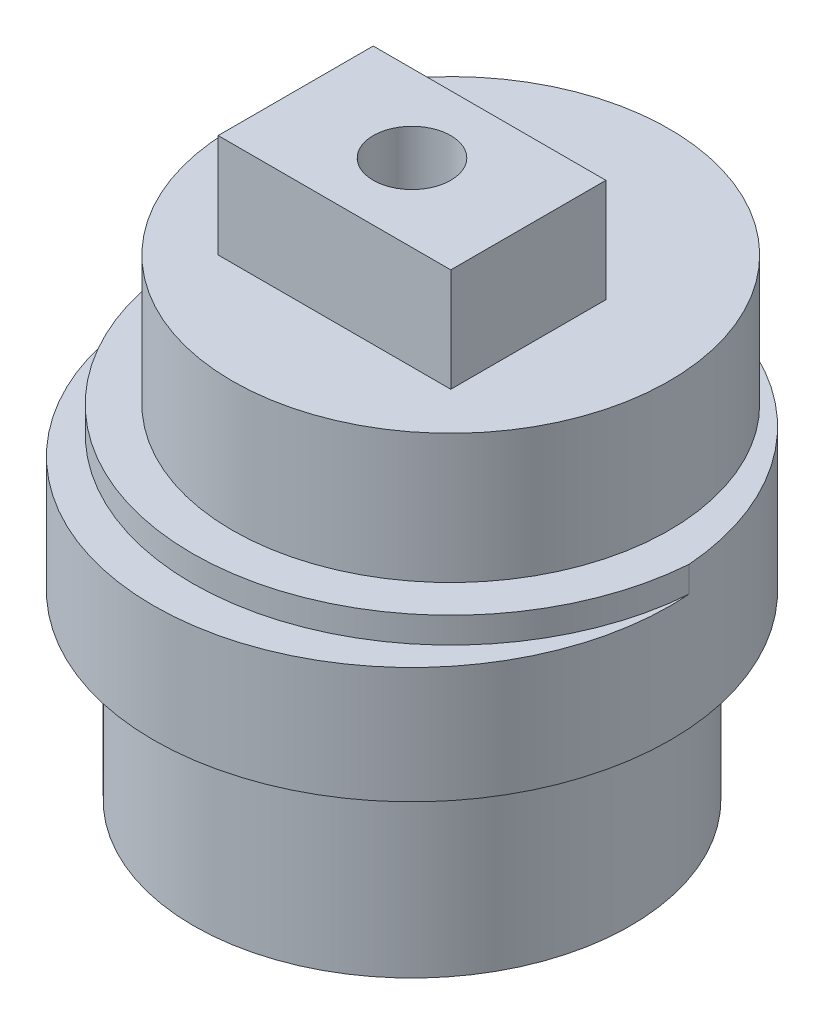
from build123d import *

# Parameters (mm, degrees)
SKETCH1_R           = 8.45
BOSS_EXTRUDE1_DEPTH = 7
SKETCH2_R           = 10
BOSS_EXTRUDE2_DEPTH = 4.5
SKETCH3_R           = 8.45
BOSS_EXTRUDE3_DEPTH = 6
SKETCH4_R           = 8.45
BOSS_EXTRUDE4_DEPTH = 1
SKETCH5_W           = 9
SKETCH5_H           = 6
BOSS_EXTRUDE5_DEPTH = 4
SKETCH6_R           = 1.5
CUT_EXTRUDE1_DEPTH  = 8
CUT_EXTRUDE3_DEPTH  = 16


with BuildPart() as part:
    # Sketch1 → Boss-Extrude1 (new body)
    with BuildSketch(Plane(origin=(0, 0, 0), x_dir=(1, 0, 0), z_dir=(0, 1, 0))):
        Circle(SKETCH1_R)
    extrude(amount=BOSS_EXTRUDE1_DEPTH)

    # Sketch2 → Boss-Extrude2 (add)
    with BuildSketch(Plane(origin=(0, 7, 0), x_dir=(1, 0, 0), z_dir=(0, 1, 0))):
        Circle(SKETCH2_R)
    extrude(amount=BOSS_EXTRUDE2_DEPTH)

    # Sketch3 → Boss-Extrude3 (add)
    with BuildSketch(Plane(origin=(0, 11.5, 0), x_dir=(1, 0, 0), z_dir=(0, 1, 0))):
        with Locations((0, 1.5)):
            Circle(SKETCH3_R)
    extrude(amount=BOSS_EXTRUDE3_DEPTH)

    # Sketch4 → Boss-Extrude4 (add)
    with BuildSketch(Plane(origin=(0, 11.5, 0), x_dir=(1, 0, 0), z_dir=(0, 1, 0))):
        with BuildLine():
            ThreePointArc((9.971835338, 0.75), (0, 10), (-9.971835338, 0.75))
            ThreePointArc((-9.971835338, 0.75), (0, -8.5), (9.971835338, 0.75))
        make_face()
        with Locations((0, 1.5)):
            Circle(SKETCH4_R, mode=Mode.SUBTRACT)
    extrude(amount=BOSS_EXTRUDE4_DEPTH)

    # Sketch5 → Boss-Extrude5 (add)
    with BuildSketch(Plane(origin=(0, 17.5, 0), x_dir=(1, 0, 0), z_dir=(0, 1, 0))):
        Rectangle(SKETCH5_W, SKETCH5_H)
    extrude(amount=BOSS_EXTRUDE5_DEPTH)

    # Sketch6 → Cut-Extrude1 (cut)
    with BuildSketch(Plane(origin=(0, 21.5, 0), x_dir=(1, 0, 0), z_dir=(0, 1, 0))):
        Circle(SKETCH6_R)
    extrude(amount=-CUT_EXTRUDE1_DEPTH, mode=Mode.SUBTRACT)

    # Sketch8 → Cut-Extrude3 (cut)
    with BuildSketch(Plane.XZ):
        with BuildLine():
            ThreePointArc((1.943316155, 2.925914586), (1.699048653, 3.074197053), (1.443536153, 3.202133229))
            add(Edge.make_bspline(
                [(1.443536153, 3.202133229), (1.444031707, 3.223830116), (1.44398849, 3.268683064), (1.440824568, 3.338668541), (1.434115766, 3.41398948), (1.423301357, 3.49507766), (1.407896176, 3.581722393), (1.387267561, 3.673599968), (1.361458781, 3.770678005), (1.325563984, 3.878324655), (1.299816317, 3.963754312), (1.269287176, 4.016921178), (1.254329579, 4.036617994), (1.237294912, 4.054558617), (1.218164406, 4.070191292), (1.19356956, 4.087238463), (1.163917734, 4.095781007), (1.134023041, 4.094432002), (1.109507694, 4.09137348), (1.085539043, 4.08524571), (1.062394745, 4.076525861), (1.008258504, 4.04775067), (0.941006014, 3.989113898), (0.85334155, 3.917064057), (0.779840002, 3.848596833), (0.713491437, 3.781776952), (0.65434972, 3.71660881), (0.602051386, 3.653703098), (0.556297725, 3.593496334), (0.516384238, 3.535921245), (0.492484438, 3.497966161), (0.481360595, 3.479331232)],
                knots=[0.027203348, 0.027203348, 0.027203348, 0.027203348, 0.05931822, 0.093555562, 0.130845058, 0.171186709, 0.214580515, 0.261026475, 0.31052459, 0.363074859, 0.429245309, 0.441417135, 0.453588962, 0.465760788, 0.477932615, 0.490104441, 0.509895559, 0.522067385, 0.534239212, 0.546411038, 0.558582865, 0.570754691, 0.636925141, 0.68947541, 0.738973525, 0.785419485, 0.828813291, 0.869154942, 0.906444438, 0.94068178, 0.972796652, 0.972796652, 0.972796652, 0.972796652], degree=3, weights=[1, 1, 1, 1, 1, 1, 1, 1, 1, 1, 1, 1, 1, 1, 1, 1, 1, 1, 1, 1, 1, 1, 1, 1, 1, 1, 1, 1, 1, 1, 1, 1]))
            ThreePointArc((0.481360595, 3.479331232), (0.196945829, 3.506945421), (-0.088772405, 3.511349214))
            add(Edge.make_bspline(
                [(-0.088772405, 3.511349214), (-0.097739853, 3.531112446), (-0.117239755, 3.571504805), (-0.15045591, 3.633186767), (-0.189180863, 3.698137748), (-0.234107151, 3.766503478), (-0.28558048, 3.837883627), (-0.344030407, 3.911712041), (-0.409403895, 3.98797832), (-0.48845012, 4.069390432), (-0.548714506, 4.135188398), (-0.59928855, 4.169843992), (-0.621311008, 4.181100352), (-0.644442858, 4.18987323), (-0.668461611, 4.195657368), (-0.698017292, 4.200345035), (-0.728439135, 4.195176156), (-0.754788011, 4.180989923), (-0.775548532, 4.16759748), (-0.794484801, 4.151676941), (-0.811553693, 4.133778694), (-0.847843672, 4.084364309), (-0.882994531, 4.00235464), (-0.930716229, 3.899403792), (-0.96723202, 3.805825828), (-0.998017952, 3.716835632), (-1.023027401, 3.632460536), (-1.042852806, 3.55309305), (-1.057952694, 3.478996861), (-1.068932609, 3.409805685), (-1.073997491, 3.365239602), (-1.075934334, 3.343623656)],
                knots=[0.027203348, 0.027203348, 0.027203348, 0.027203348, 0.05931822, 0.093555562, 0.130845058, 0.171186709, 0.214580515, 0.261026475, 0.31052459, 0.363074859, 0.429245309, 0.441417135, 0.453588962, 0.465760788, 0.477932615, 0.490104441, 0.509895559, 0.522067385, 0.534239212, 0.546411038, 0.558582865, 0.570754691, 0.636925141, 0.68947541, 0.738973525, 0.785419485, 0.828813291, 0.869154942, 0.906444438, 0.94068178, 0.972796652, 0.972796652, 0.972796652, 0.972796652], degree=3, weights=[1, 1, 1, 1, 1, 1, 1, 1, 1, 1, 1, 1, 1, 1, 1, 1, 1, 1, 1, 1, 1, 1, 1, 1, 1, 1, 1, 1, 1, 1, 1, 1]))
            ThreePointArc((-1.075934334, 3.343623656), (-1.344164531, 3.245100238), (-1.603498499, 3.125099423))
            add(Edge.make_bspline(
                [(-1.603498499, 3.125099423), (-1.620152836, 3.13901465), (-1.655247228, 3.166946218), (-1.71193675, 3.208107795), (-1.775007901, 3.24982448), (-1.845147867, 3.291927088), (-1.922494421, 3.33390494), (-2.007188933, 3.37506157), (-2.099179109, 3.415410619), (-2.205720688, 3.454463526), (-2.288565692, 3.487597708), (-2.349167829, 3.496878064), (-2.37389333, 3.497464507), (-2.398540815, 3.495332064), (-2.422690608, 3.490122045), (-2.451353259, 3.481521758), (-2.476519699, 3.463665216), (-2.49410404, 3.439451513), (-2.506997861, 3.418377686), (-2.517151187, 3.395817637), (-2.524763968, 3.372285959), (-2.536020012, 3.312019505), (-2.532107179, 3.22287996), (-2.530434245, 3.109418782), (-2.522731879, 3.009264342), (-2.511857646, 2.915729431), (-2.497781398, 2.828858903), (-2.48120721, 2.748749348), (-2.462662608, 2.675439393), (-2.442534243, 2.608336291), (-2.427761045, 2.565986067), (-2.420127273, 2.545670408)],
                knots=[0.027203348, 0.027203348, 0.027203348, 0.027203348, 0.05931822, 0.093555562, 0.130845058, 0.171186709, 0.214580515, 0.261026475, 0.31052459, 0.363074859, 0.429245309, 0.441417135, 0.453588962, 0.465760788, 0.477932615, 0.490104441, 0.509895559, 0.522067385, 0.534239212, 0.546411038, 0.558582865, 0.570754691, 0.636925141, 0.68947541, 0.738973525, 0.785419485, 0.828813291, 0.869154942, 0.906444438, 0.94068178, 0.972796652, 0.972796652, 0.972796652, 0.972796652], degree=3, weights=[1, 1, 1, 1, 1, 1, 1, 1, 1, 1, 1, 1, 1, 1, 1, 1, 1, 1, 1, 1, 1, 1, 1, 1, 1, 1, 1, 1, 1, 1, 1, 1]))
            ThreePointArc((-2.420127273, 2.545670408), (-2.619046621, 2.340523155), (-2.800632051, 2.119885365))
            add(Edge.make_bspline(
                [(-2.800632051, 2.119885365), (-2.82167468, 2.125196505), (-2.865412688, 2.135135092), (-2.934347522, 2.14762373), (-3.009272856, 2.157843617), (-3.090734419, 2.165344166), (-3.178634763, 2.169605492), (-3.272799074, 2.169938763), (-3.373186155, 2.166378958), (-3.486121223, 2.155337752), (-3.575138375, 2.149245519), (-3.63376561, 2.131312549), (-3.656296964, 2.121112923), (-3.677578348, 2.108497515), (-3.697076017, 2.093325248), (-3.719168648, 2.073140399), (-3.734095165, 2.046132902), (-3.739432177, 2.016687549), (-3.741905517, 1.992106268), (-3.741264909, 1.967375003), (-3.737913776, 1.942870632), (-3.721906486, 1.883688618), (-3.679704947, 1.805074378), (-3.628968725, 1.703575248), (-3.57857375, 1.616681147), (-3.528193127, 1.537127257), (-3.477819157, 1.46496707), (-3.428128096, 1.399982127), (-3.379611989, 1.341978341), (-3.332362014, 1.290253905), (-3.300676749, 1.258507522), (-3.284984324, 1.243515915)],
                knots=[0.027203348, 0.027203348, 0.027203348, 0.027203348, 0.05931822, 0.093555562, 0.130845058, 0.171186709, 0.214580515, 0.261026475, 0.31052459, 0.363074859, 0.429245309, 0.441417135, 0.453588962, 0.465760788, 0.477932615, 0.490104441, 0.509895559, 0.522067385, 0.534239212, 0.546411038, 0.558582865, 0.570754691, 0.636925141, 0.68947541, 0.738973525, 0.785419485, 0.828813291, 0.869154942, 0.906444438, 0.94068178, 0.972796652, 0.972796652, 0.972796652, 0.972796652], degree=3, weights=[1, 1, 1, 1, 1, 1, 1, 1, 1, 1, 1, 1, 1, 1, 1, 1, 1, 1, 1, 1, 1, 1, 1, 1, 1, 1, 1, 1, 1, 1, 1, 1]))
            ThreePointArc((-3.284984324, 1.243515915), (-3.375194407, 0.972376756), (-3.443066077, 0.694802011))
            add(Edge.make_bspline(
                [(-3.443066077, 0.694802011), (-3.464329248, 0.690457129), (-3.508048023, 0.680434275), (-3.575574779, 0.661776446), (-3.647514416, 0.638475362), (-3.724163113, 0.609888276), (-3.805207507, 0.575589068), (-3.890191221, 0.535032971), (-3.979092314, 0.488269375), (-4.076052694, 0.429320903), (-4.153611056, 0.385208897), (-4.198651546, 0.343614445), (-4.214526143, 0.324648911), (-4.228226387, 0.304049175), (-4.23921018, 0.281919713), (-4.250357075, 0.254148159), (-4.252087287, 0.223338872), (-4.244119909, 0.194493883), (-4.235682894, 0.171273772), (-4.224375232, 0.149269622), (-4.210723917, 0.128645949), (-4.170623734, 0.082270099), (-4.098492021, 0.029751678), (-4.008741442, -0.039682257), (-3.925635201, -0.096105576), (-3.845726689, -0.145921822), (-3.769032179, -0.189079457), (-3.69606617, -0.226068725), (-3.627187768, -0.25727798), (-3.56217462, -0.283379091), (-3.519852944, -0.298233872), (-3.499209943, -0.304932155)],
                knots=[0.027203348, 0.027203348, 0.027203348, 0.027203348, 0.05931822, 0.093555562, 0.130845058, 0.171186709, 0.214580515, 0.261026475, 0.31052459, 0.363074859, 0.429245309, 0.441417135, 0.453588962, 0.465760788, 0.477932615, 0.490104441, 0.509895559, 0.522067385, 0.534239212, 0.546411038, 0.558582865, 0.570754691, 0.636925141, 0.68947541, 0.738973525, 0.785419485, 0.828813291, 0.869154942, 0.906444438, 0.94068178, 0.972796652, 0.972796652, 0.972796652, 0.972796652], degree=3, weights=[1, 1, 1, 1, 1, 1, 1, 1, 1, 1, 1, 1, 1, 1, 1, 1, 1, 1, 1, 1, 1, 1, 1, 1, 1, 1, 1, 1, 1, 1, 1, 1]))
            ThreePointArc((-3.499209943, -0.304932155), (-3.462843547, -0.588360784), (-3.40355864, -0.867895402))
            add(Edge.make_bspline(
                [(-3.40355864, -0.867895402), (-3.420830922, -0.88103575), (-3.455871423, -0.909034894), (-3.5086156, -0.955143779), (-3.563321011, -1.007350769), (-3.61997563, -1.066363467), (-3.678112237, -1.132429831), (-3.737083286, -1.205842663), (-3.79689044, -1.286547945), (-3.858671941, -1.381728216), (-3.909410127, -1.455123072), (-3.93194305, -1.512140715), (-3.938016731, -1.5361158), (-3.941422334, -1.560619834), (-3.941716776, -1.585323479), (-3.939710156, -1.615181241), (-3.927901374, -1.643690161), (-3.908207643, -1.666221682), (-3.890531326, -1.683481595), (-3.870796232, -1.698400439), (-3.849548546, -1.711058643), (-3.793297802, -1.735443022), (-3.705522485, -1.751463707), (-3.594533753, -1.775080204), (-3.495176456, -1.789857412), (-3.401566916, -1.800069294), (-3.313742153, -1.805676479), (-3.231953009, -1.807343893), (-3.156354525, -1.805577242), (-3.086454855, -1.800885382), (-3.041879094, -1.795906391), (-3.020374117, -1.792984673)],
                knots=[0.027203348, 0.027203348, 0.027203348, 0.027203348, 0.05931822, 0.093555562, 0.130845058, 0.171186709, 0.214580515, 0.261026475, 0.31052459, 0.363074859, 0.429245309, 0.441417135, 0.453588962, 0.465760788, 0.477932615, 0.490104441, 0.509895559, 0.522067385, 0.534239212, 0.546411038, 0.558582865, 0.570754691, 0.636925141, 0.68947541, 0.738973525, 0.785419485, 0.828813291, 0.869154942, 0.906444438, 0.94068178, 0.972796652, 0.972796652, 0.972796652, 0.972796652], degree=3, weights=[1, 1, 1, 1, 1, 1, 1, 1, 1, 1, 1, 1, 1, 1, 1, 1, 1, 1, 1, 1, 1, 1, 1, 1, 1, 1, 1, 1, 1, 1, 1, 1]))
            ThreePointArc((-3.020374117, -1.792984673), (-2.864634053, -2.032566256), (-2.689934673, -2.258695486))
            add(Edge.make_bspline(
                [(-2.689934673, -2.258695486), (-2.699795077, -2.278028694), (-2.719217105, -2.318458555), (-2.746732071, -2.382886065), (-2.773368179, -2.453658726), (-2.798807576, -2.531408848), (-2.822521729, -2.616157113), (-2.843800174, -2.707886368), (-2.862667848, -2.806548667), (-2.877033885, -2.919109116), (-2.890902577, -3.007250071), (-2.886465011, -3.06839786), (-2.881534809, -3.092633937), (-2.873971249, -3.116188945), (-2.863518022, -3.138573914), (-2.848755322, -3.164604188), (-2.825746421, -3.185166199), (-2.798226922, -3.196921608), (-2.774812315, -3.204802786), (-2.750558566, -3.209681463), (-2.725922874, -3.211867086), (-2.664662719, -3.209430369), (-2.578628776, -3.185780225), (-2.46838457, -3.158901747), (-2.372455148, -3.129106036), (-2.283685097, -3.097690966), (-2.202124854, -3.064637129), (-2.127711918, -3.030652437), (-2.060366558, -2.996259787), (-1.999424853, -2.961704237), (-1.961423784, -2.937877623), (-1.943316155, -2.925914586)],
                knots=[0.027203348, 0.027203348, 0.027203348, 0.027203348, 0.05931822, 0.093555562, 0.130845058, 0.171186709, 0.214580515, 0.261026475, 0.31052459, 0.363074859, 0.429245309, 0.441417135, 0.453588962, 0.465760788, 0.477932615, 0.490104441, 0.509895559, 0.522067385, 0.534239212, 0.546411038, 0.558582865, 0.570754691, 0.636925141, 0.68947541, 0.738973525, 0.785419485, 0.828813291, 0.869154942, 0.906444438, 0.94068178, 0.972796652, 0.972796652, 0.972796652, 0.972796652], degree=3, weights=[1, 1, 1, 1, 1, 1, 1, 1, 1, 1, 1, 1, 1, 1, 1, 1, 1, 1, 1, 1, 1, 1, 1, 1, 1, 1, 1, 1, 1, 1, 1, 1]))
            ThreePointArc((-1.943316155, -2.925914586), (-1.699048653, -3.074197053), (-1.443536153, -3.202133229))
            add(Edge.make_bspline(
                [(-1.443536153, -3.202133229), (-1.444031707, -3.223830116), (-1.44398849, -3.268683064), (-1.440824568, -3.338668541), (-1.434115766, -3.41398948), (-1.423301357, -3.49507766), (-1.407896176, -3.581722393), (-1.387267561, -3.673599968), (-1.361458781, -3.770678005), (-1.325563984, -3.878324655), (-1.299816317, -3.963754312), (-1.269287176, -4.016921178), (-1.254329579, -4.036617994), (-1.237294912, -4.054558617), (-1.218164406, -4.070191292), (-1.19356956, -4.087238463), (-1.163917734, -4.095781007), (-1.134023041, -4.094432002), (-1.109507694, -4.09137348), (-1.085539043, -4.08524571), (-1.062394745, -4.076525861), (-1.008258504, -4.04775067), (-0.941006014, -3.989113898), (-0.85334155, -3.917064057), (-0.779840002, -3.848596833), (-0.713491437, -3.781776952), (-0.65434972, -3.71660881), (-0.602051386, -3.653703098), (-0.556297725, -3.593496334), (-0.516384238, -3.535921245), (-0.492484438, -3.497966161), (-0.481360595, -3.479331232)],
                knots=[0.027203348, 0.027203348, 0.027203348, 0.027203348, 0.05931822, 0.093555562, 0.130845058, 0.171186709, 0.214580515, 0.261026475, 0.31052459, 0.363074859, 0.429245309, 0.441417135, 0.453588962, 0.465760788, 0.477932615, 0.490104441, 0.509895559, 0.522067385, 0.534239212, 0.546411038, 0.558582865, 0.570754691, 0.636925141, 0.68947541, 0.738973525, 0.785419485, 0.828813291, 0.869154942, 0.906444438, 0.94068178, 0.972796652, 0.972796652, 0.972796652, 0.972796652], degree=3, weights=[1, 1, 1, 1, 1, 1, 1, 1, 1, 1, 1, 1, 1, 1, 1, 1, 1, 1, 1, 1, 1, 1, 1, 1, 1, 1, 1, 1, 1, 1, 1, 1]))
            ThreePointArc((-0.481360595, -3.479331232), (-0.196945829, -3.506945421), (0.088772405, -3.511349214))
            add(Edge.make_bspline(
                [(0.088772405, -3.511349214), (0.097739853, -3.531112446), (0.117239755, -3.571504805), (0.15045591, -3.633186767), (0.189180863, -3.698137748), (0.234107151, -3.766503478), (0.28558048, -3.837883627), (0.344030407, -3.911712041), (0.409403895, -3.98797832), (0.48845012, -4.069390432), (0.548714506, -4.135188398), (0.59928855, -4.169843992), (0.621311008, -4.181100352), (0.644442858, -4.18987323), (0.668461611, -4.195657368), (0.698017292, -4.200345035), (0.728439135, -4.195176156), (0.754788011, -4.180989923), (0.775548532, -4.16759748), (0.794484801, -4.151676941), (0.811553693, -4.133778694), (0.847843672, -4.084364309), (0.882994531, -4.00235464), (0.930716229, -3.899403792), (0.96723202, -3.805825828), (0.998017952, -3.716835632), (1.023027401, -3.632460536), (1.042852806, -3.55309305), (1.057952694, -3.478996861), (1.068932609, -3.409805685), (1.073997491, -3.365239602), (1.075934334, -3.343623656)],
                knots=[0.027203348, 0.027203348, 0.027203348, 0.027203348, 0.05931822, 0.093555562, 0.130845058, 0.171186709, 0.214580515, 0.261026475, 0.31052459, 0.363074859, 0.429245309, 0.441417135, 0.453588962, 0.465760788, 0.477932615, 0.490104441, 0.509895559, 0.522067385, 0.534239212, 0.546411038, 0.558582865, 0.570754691, 0.636925141, 0.68947541, 0.738973525, 0.785419485, 0.828813291, 0.869154942, 0.906444438, 0.94068178, 0.972796652, 0.972796652, 0.972796652, 0.972796652], degree=3, weights=[1, 1, 1, 1, 1, 1, 1, 1, 1, 1, 1, 1, 1, 1, 1, 1, 1, 1, 1, 1, 1, 1, 1, 1, 1, 1, 1, 1, 1, 1, 1, 1]))
            ThreePointArc((1.075934334, -3.343623656), (1.344164531, -3.245100238), (1.603498499, -3.125099423))
            add(Edge.make_bspline(
                [(1.603498499, -3.125099423), (1.620152836, -3.13901465), (1.655247228, -3.166946218), (1.71193675, -3.208107795), (1.775007901, -3.24982448), (1.845147867, -3.291927088), (1.922494421, -3.33390494), (2.007188933, -3.37506157), (2.099179109, -3.415410619), (2.205720688, -3.454463526), (2.288565692, -3.487597708), (2.349167829, -3.496878064), (2.37389333, -3.497464507), (2.398540815, -3.495332064), (2.422690608, -3.490122045), (2.451353259, -3.481521758), (2.476519699, -3.463665216), (2.49410404, -3.439451513), (2.506997861, -3.418377686), (2.517151187, -3.395817637), (2.524763968, -3.372285959), (2.536020012, -3.312019505), (2.532107179, -3.22287996), (2.530434245, -3.109418782), (2.522731879, -3.009264342), (2.511857646, -2.915729431), (2.497781398, -2.828858903), (2.48120721, -2.748749348), (2.462662608, -2.675439393), (2.442534243, -2.608336291), (2.427761045, -2.565986067), (2.420127273, -2.545670408)],
                knots=[0.027203348, 0.027203348, 0.027203348, 0.027203348, 0.05931822, 0.093555562, 0.130845058, 0.171186709, 0.214580515, 0.261026475, 0.31052459, 0.363074859, 0.429245309, 0.441417135, 0.453588962, 0.465760788, 0.477932615, 0.490104441, 0.509895559, 0.522067385, 0.534239212, 0.546411038, 0.558582865, 0.570754691, 0.636925141, 0.68947541, 0.738973525, 0.785419485, 0.828813291, 0.869154942, 0.906444438, 0.94068178, 0.972796652, 0.972796652, 0.972796652, 0.972796652], degree=3, weights=[1, 1, 1, 1, 1, 1, 1, 1, 1, 1, 1, 1, 1, 1, 1, 1, 1, 1, 1, 1, 1, 1, 1, 1, 1, 1, 1, 1, 1, 1, 1, 1]))
            ThreePointArc((2.420127273, -2.545670408), (2.619046621, -2.340523155), (2.800632051, -2.119885365))
            add(Edge.make_bspline(
                [(2.800632051, -2.119885365), (2.82167468, -2.125196505), (2.865412688, -2.135135092), (2.934347522, -2.14762373), (3.009272856, -2.157843617), (3.090734419, -2.165344166), (3.178634763, -2.169605492), (3.272799074, -2.169938763), (3.373186155, -2.166378958), (3.486121223, -2.155337752), (3.575138375, -2.149245519), (3.63376561, -2.131312549), (3.656296964, -2.121112923), (3.677578348, -2.108497515), (3.697076017, -2.093325248), (3.719168648, -2.073140399), (3.734095165, -2.046132902), (3.739432177, -2.016687549), (3.741905517, -1.992106268), (3.741264909, -1.967375003), (3.737913776, -1.942870632), (3.721906486, -1.883688618), (3.679704947, -1.805074378), (3.628968725, -1.703575248), (3.57857375, -1.616681147), (3.528193127, -1.537127257), (3.477819157, -1.46496707), (3.428128096, -1.399982127), (3.379611989, -1.341978341), (3.332362014, -1.290253905), (3.300676749, -1.258507522), (3.284984324, -1.243515915)],
                knots=[0.027203348, 0.027203348, 0.027203348, 0.027203348, 0.05931822, 0.093555562, 0.130845058, 0.171186709, 0.214580515, 0.261026475, 0.31052459, 0.363074859, 0.429245309, 0.441417135, 0.453588962, 0.465760788, 0.477932615, 0.490104441, 0.509895559, 0.522067385, 0.534239212, 0.546411038, 0.558582865, 0.570754691, 0.636925141, 0.68947541, 0.738973525, 0.785419485, 0.828813291, 0.869154942, 0.906444438, 0.94068178, 0.972796652, 0.972796652, 0.972796652, 0.972796652], degree=3, weights=[1, 1, 1, 1, 1, 1, 1, 1, 1, 1, 1, 1, 1, 1, 1, 1, 1, 1, 1, 1, 1, 1, 1, 1, 1, 1, 1, 1, 1, 1, 1, 1]))
            ThreePointArc((3.284984324, -1.243515915), (3.375194407, -0.972376756), (3.443066077, -0.694802011))
            add(Edge.make_bspline(
                [(3.443066077, -0.694802011), (3.464329248, -0.690457129), (3.508048023, -0.680434275), (3.575574779, -0.661776446), (3.647514416, -0.638475362), (3.724163113, -0.609888276), (3.805207507, -0.575589068), (3.890191221, -0.535032971), (3.979092314, -0.488269375), (4.076052694, -0.429320903), (4.153611056, -0.385208897), (4.198651546, -0.343614445), (4.214526143, -0.324648911), (4.228226387, -0.304049175), (4.23921018, -0.281919713), (4.250357075, -0.254148159), (4.252087287, -0.223338872), (4.244119909, -0.194493883), (4.235682894, -0.171273772), (4.224375232, -0.149269622), (4.210723917, -0.128645949), (4.170623734, -0.082270099), (4.098492021, -0.029751678), (4.008741442, 0.039682257), (3.925635201, 0.096105576), (3.845726689, 0.145921822), (3.769032179, 0.189079457), (3.69606617, 0.226068725), (3.627187768, 0.25727798), (3.56217462, 0.283379091), (3.519852944, 0.298233872), (3.499209943, 0.304932155)],
                knots=[0.027203348, 0.027203348, 0.027203348, 0.027203348, 0.05931822, 0.093555562, 0.130845058, 0.171186709, 0.214580515, 0.261026475, 0.31052459, 0.363074859, 0.429245309, 0.441417135, 0.453588962, 0.465760788, 0.477932615, 0.490104441, 0.509895559, 0.522067385, 0.534239212, 0.546411038, 0.558582865, 0.570754691, 0.636925141, 0.68947541, 0.738973525, 0.785419485, 0.828813291, 0.869154942, 0.906444438, 0.94068178, 0.972796652, 0.972796652, 0.972796652, 0.972796652], degree=3, weights=[1, 1, 1, 1, 1, 1, 1, 1, 1, 1, 1, 1, 1, 1, 1, 1, 1, 1, 1, 1, 1, 1, 1, 1, 1, 1, 1, 1, 1, 1, 1, 1]))
            ThreePointArc((3.499209943, 0.304932155), (3.462843547, 0.588360784), (3.40355864, 0.867895402))
            add(Edge.make_bspline(
                [(3.40355864, 0.867895402), (3.420830922, 0.88103575), (3.455871423, 0.909034894), (3.5086156, 0.955143779), (3.563321011, 1.007350769), (3.61997563, 1.066363467), (3.678112237, 1.132429831), (3.737083286, 1.205842663), (3.79689044, 1.286547945), (3.858671941, 1.381728216), (3.909410127, 1.455123072), (3.93194305, 1.512140715), (3.938016731, 1.5361158), (3.941422334, 1.560619834), (3.941716776, 1.585323479), (3.939710156, 1.615181241), (3.927901374, 1.643690161), (3.908207643, 1.666221682), (3.890531326, 1.683481595), (3.870796232, 1.698400439), (3.849548546, 1.711058643), (3.793297802, 1.735443022), (3.705522485, 1.751463707), (3.594533753, 1.775080204), (3.495176456, 1.789857412), (3.401566916, 1.800069294), (3.313742153, 1.805676479), (3.231953009, 1.807343893), (3.156354525, 1.805577242), (3.086454855, 1.800885382), (3.041879094, 1.795906391), (3.020374117, 1.792984673)],
                knots=[0.027203348, 0.027203348, 0.027203348, 0.027203348, 0.05931822, 0.093555562, 0.130845058, 0.171186709, 0.214580515, 0.261026475, 0.31052459, 0.363074859, 0.429245309, 0.441417135, 0.453588962, 0.465760788, 0.477932615, 0.490104441, 0.509895559, 0.522067385, 0.534239212, 0.546411038, 0.558582865, 0.570754691, 0.636925141, 0.68947541, 0.738973525, 0.785419485, 0.828813291, 0.869154942, 0.906444438, 0.94068178, 0.972796652, 0.972796652, 0.972796652, 0.972796652], degree=3, weights=[1, 1, 1, 1, 1, 1, 1, 1, 1, 1, 1, 1, 1, 1, 1, 1, 1, 1, 1, 1, 1, 1, 1, 1, 1, 1, 1, 1, 1, 1, 1, 1]))
            ThreePointArc((3.020374117, 1.792984673), (2.864634053, 2.032566256), (2.689934673, 2.258695486))
            add(Edge.make_bspline(
                [(2.689934673, 2.258695486), (2.699795077, 2.278028694), (2.719217105, 2.318458555), (2.746732071, 2.382886065), (2.773368179, 2.453658726), (2.798807576, 2.531408848), (2.822521729, 2.616157113), (2.843800174, 2.707886368), (2.862667848, 2.806548667), (2.877033885, 2.919109116), (2.890902577, 3.007250071), (2.886465011, 3.06839786), (2.881534809, 3.092633937), (2.873971249, 3.116188945), (2.863518022, 3.138573914), (2.848755322, 3.164604188), (2.825746421, 3.185166199), (2.798226922, 3.196921608), (2.774812315, 3.204802786), (2.750558566, 3.209681463), (2.725922874, 3.211867086), (2.664662719, 3.209430369), (2.578628776, 3.185780225), (2.46838457, 3.158901747), (2.372455148, 3.129106036), (2.283685097, 3.097690966), (2.202124854, 3.064637129), (2.127711918, 3.030652437), (2.060366558, 2.996259787), (1.999424853, 2.961704237), (1.961423784, 2.937877623), (1.943316155, 2.925914586)],
                knots=[0.027203348, 0.027203348, 0.027203348, 0.027203348, 0.05931822, 0.093555562, 0.130845058, 0.171186709, 0.214580515, 0.261026475, 0.31052459, 0.363074859, 0.429245309, 0.441417135, 0.453588962, 0.465760788, 0.477932615, 0.490104441, 0.509895559, 0.522067385, 0.534239212, 0.546411038, 0.558582865, 0.570754691, 0.636925141, 0.68947541, 0.738973525, 0.785419485, 0.828813291, 0.869154942, 0.906444438, 0.94068178, 0.972796652, 0.972796652, 0.972796652, 0.972796652], degree=3, weights=[1, 1, 1, 1, 1, 1, 1, 1, 1, 1, 1, 1, 1, 1, 1, 1, 1, 1, 1, 1, 1, 1, 1, 1, 1, 1, 1, 1, 1, 1, 1, 1]))
        make_face()
    extrude(amount=-CUT_EXTRUDE3_DEPTH, mode=Mode.SUBTRACT)


solid = part.part
